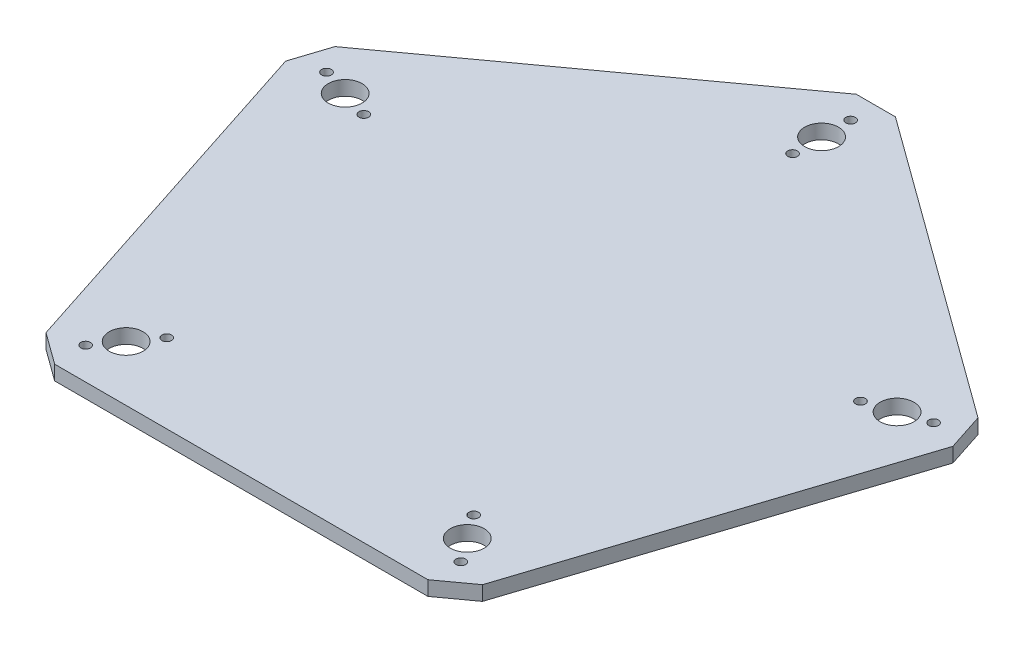
from build123d import *

# Parameters (mm, degrees)
ESQUISSE2_R        = 3.5
ESQUISSE2_R_2      = 1
BOSS_EXTRU_1_DEPTH = 3
CHANFREIN1_SIZE    = 5


with BuildPart() as part:
    # Esquisse2 → Boss.-Extru.1 (new body)
    with BuildSketch(Plane(origin=(0, 0, 0), x_dir=(1, 0, 0), z_dir=(0, 1, 0))):
        Polygon((70.534230275, 22.917960675), (0, 74.16407865), (-70.534230275, 22.917960675), (-43.59255168, -60), (43.59255168, -60), align=None)
        with Locations((-57.063390978, 18.541019662)):
            Circle(ESQUISSE2_R, mode=Mode.SUBTRACT)
        with Locations((0, 60)):
            Circle(ESQUISSE2_R, mode=Mode.SUBTRACT)
        with Locations((57.063390978, 18.541019662)):
            Circle(ESQUISSE2_R, mode=Mode.SUBTRACT)
        with Locations((35.267115138, -48.541019662)):
            Circle(ESQUISSE2_R, mode=Mode.SUBTRACT)
        with Locations((-35.267115138, -48.541019662)):
            Circle(ESQUISSE2_R, mode=Mode.SUBTRACT)
        with Locations((-62.769730075, 20.395121629)):
            Circle(ESQUISSE2_R_2, mode=Mode.SUBTRACT)
        with Locations((-51.35705188, 16.686917696)):
            Circle(ESQUISSE2_R_2, mode=Mode.SUBTRACT)
        with Locations((0, 66)):
            Circle(ESQUISSE2_R_2, mode=Mode.SUBTRACT)
        with Locations((0, 54)):
            Circle(ESQUISSE2_R_2, mode=Mode.SUBTRACT)
        with Locations((62.769730075, 20.395121629)):
            Circle(ESQUISSE2_R_2, mode=Mode.SUBTRACT)
        with Locations((51.35705188, 16.686917696)):
            Circle(ESQUISSE2_R_2, mode=Mode.SUBTRACT)
        with Locations((38.793826651, -53.395121629)):
            Circle(ESQUISSE2_R_2, mode=Mode.SUBTRACT)
        with Locations((31.740403624, -43.686917696)):
            Circle(ESQUISSE2_R_2, mode=Mode.SUBTRACT)
        with Locations((-38.793826651, -53.395121629)):
            Circle(ESQUISSE2_R_2, mode=Mode.SUBTRACT)
        with Locations((-31.740403624, -43.686917696)):
            Circle(ESQUISSE2_R_2, mode=Mode.SUBTRACT)
    extrude(amount=BOSS_EXTRU_1_DEPTH)

    # Chanfrein1
    chanfrein1_edges = [part.edges().sort_by_distance(p)[0] for p in [
        (43.59255168, 1.5, 60),
        (-43.59255168, 1.5, 60),
        (-70.534230275, 1.5, -22.917960675),
        (0, 1.5, -74.16407865),
        (70.534230275, 1.5, -22.917960675),
    ]]
    chamfer(chanfrein1_edges, length=CHANFREIN1_SIZE)


solid = part.part
